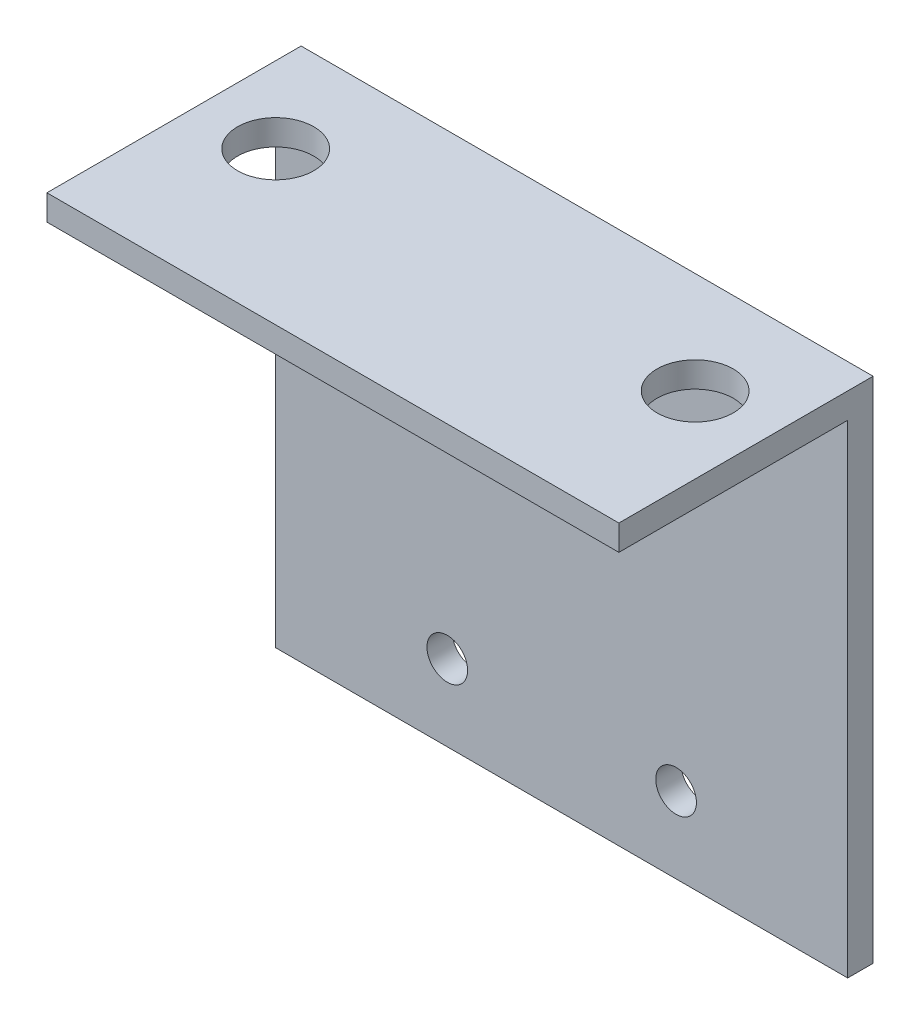
from build123d import *

# Parameters (mm, degrees)
EXTRUDE_1_DEPTH     = 45
SKETCH_2_R          = 3
CUT_EXTRUDE_1_DEPTH = 3
SKETCH_3_R          = 2.6
CUT_EXTRUDE_2_DEPTH = 3
SKETCH_4_R          = 1.6
CUT_EXTRUDE_3_DEPTH = 3


with BuildPart() as part:
    # ｽｹｯﾁ1 → ﾎﾞｽ - 押し出し1 (new body)
    with BuildSketch(Plane(origin=(0, 0, 0), x_dir=(0, 0, -1), z_dir=(1, 0, 0))):
        Polygon((-18, 40), (-18, 38), (0, 38), (0, 0), (2, 0), (2, 40), align=None)
    extrude(amount=EXTRUDE_1_DEPTH)

    # ｽｹｯﾁ2 → ｶｯﾄ - 押し出し1 (cut, through all)
    with BuildSketch(Plane.XZ.offset(-38)):
        with Locations((6, 6)):
            Circle(SKETCH_2_R)
        with Locations((39, 6)):
            Circle(SKETCH_2_R)
    extrude(amount=-CUT_EXTRUDE_1_DEPTH, mode=Mode.SUBTRACT)

    # ｽｹｯﾁ3 → ｶｯﾄ - 押し出し2 (cut, through all)
    with BuildSketch(Plane.XY):
        with Locations((22.5, 25)):
            Circle(SKETCH_3_R)
    extrude(amount=-CUT_EXTRUDE_2_DEPTH, mode=Mode.SUBTRACT)

    # ｽｹｯﾁ4 → ｶｯﾄ - 押し出し3 (cut, through all)
    with BuildSketch(Plane.XY):
        with Locations((13.5, 6)):
            Circle(SKETCH_4_R)
        with Locations((31.5, 6)):
            Circle(SKETCH_4_R)
    extrude(amount=-CUT_EXTRUDE_3_DEPTH, mode=Mode.SUBTRACT)


solid = part.part
